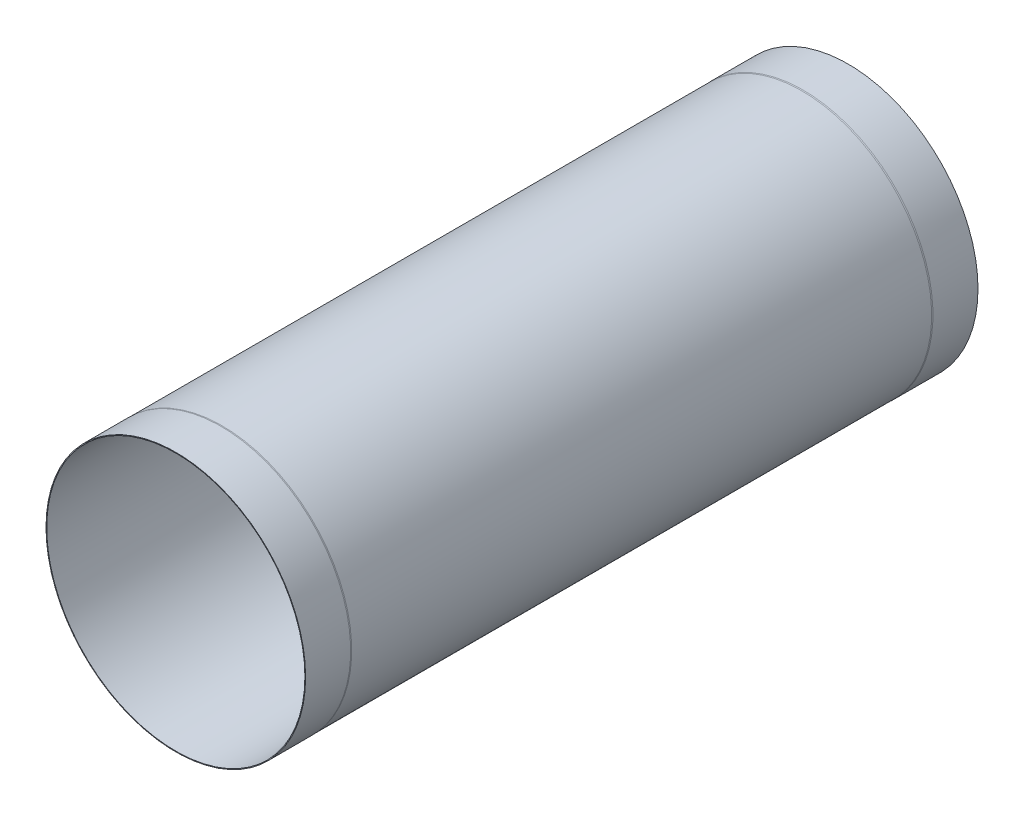
from build123d import *

# Parameters (mm, degrees)
SKETCH1_R      = 216.126
SKETCH1_R_2    = 214.95
EXTRUDE1_DEPTH = 559.8


with BuildPart() as part:
    # Sketch1 → Extrude1 (new body, symmetric)
    with BuildSketch(Plane.XY):
        Circle(SKETCH1_R)
        Circle(SKETCH1_R_2, mode=Mode.SUBTRACT)
    extrude(amount=EXTRUDE1_DEPTH, both=True)

    # Sketch2 → Cut-Revolve1 (revolve, cut)
    with BuildSketch(Plane(origin=(0, 0, 0), x_dir=(1, 0, 0), z_dir=(0, 1, 0)), mode=Mode.PRIVATE) as cut_revolve1_sk:
        Polygon((216.126, 484.8), (215.905, 482.8), (215.905, -482.8), (216.126, -484.8), align=None)
    revolve(cut_revolve1_sk.sketch.rotate(Axis((0, 0, -624.558028957), (0, 0, 1)), 180), axis=Axis((0, 0, -624.558028957), (0, 0, 1)), mode=Mode.SUBTRACT)  # turned: the seam where the file's is


solid = part.part
